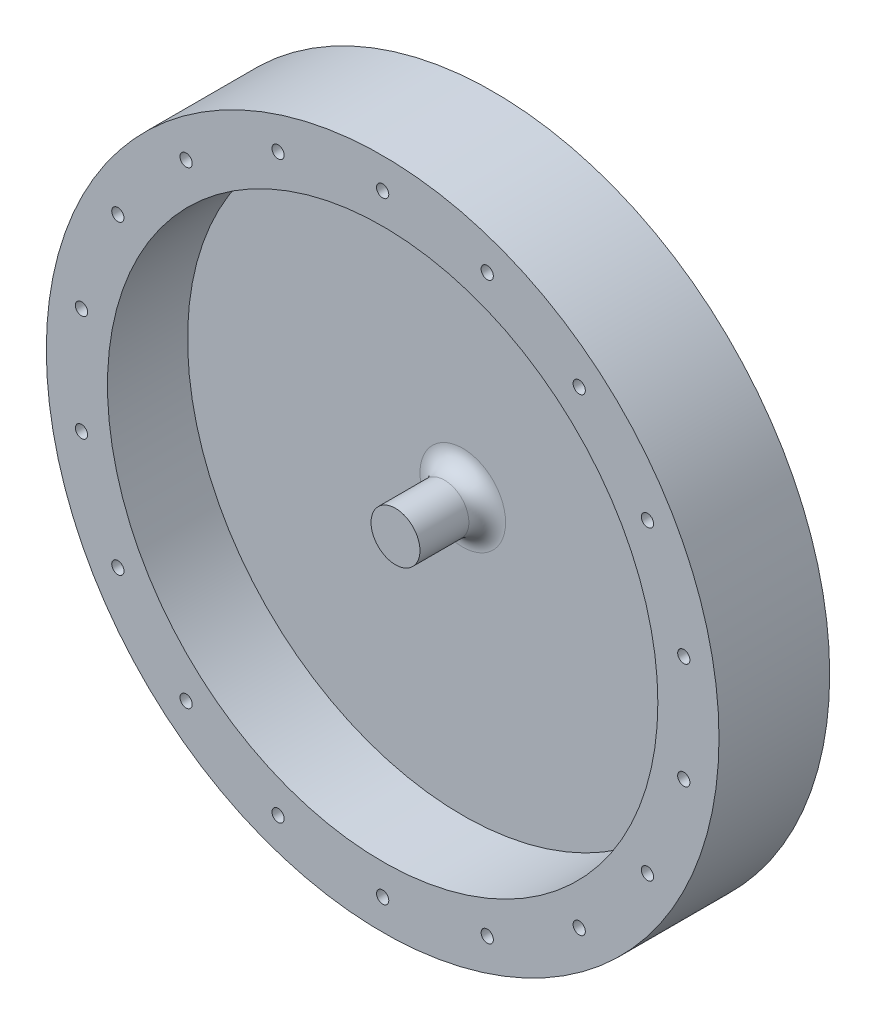
from build123d import *

# Parameters (mm, degrees)
SKETCH1_R                = 4
SKETCH1_R_2              = 2
BOSS_EXTRUDE1_DEPTH      = 8
BOSS_EXTRUDE2_START      = -8
SKETCH2_R                = 45
SKETCH2_R_2              = 4
BOSS_EXTRUDE2_DEPTH      = 5
BOSS_EXTRUDE3_START      = -8
SKETCH3_R                = 55
SKETCH3_R_2              = 45
BOSS_EXTRUDE3_DEPTH      = 18.1
SKETCH4_R                = 2
BOSS_EXTRUDE4_DEPTH      = 2
SKETCH5_R                = 1
CUT_EXTRUDE1_DEPTH       = 5
CIRPATTERN1_COUNT        = 18
MIRROR1_COPY_1_SKETCH_R  = 1
MIRROR1_COPY_1_DEPTH     = 5
MIRROR1_COPY_2_SKETCH_R  = 1
MIRROR1_COPY_2_DEPTH     = 5
MIRROR1_COPY_3_SKETCH_R  = 1
MIRROR1_COPY_3_DEPTH     = 5
MIRROR1_COPY_4_SKETCH_R  = 1
MIRROR1_COPY_4_DEPTH     = 5
MIRROR1_COPY_5_SKETCH_R  = 1
MIRROR1_COPY_5_DEPTH     = 5
MIRROR1_COPY_6_SKETCH_R  = 1
MIRROR1_COPY_6_DEPTH     = 5
MIRROR1_COPY_7_SKETCH_R  = 1
MIRROR1_COPY_7_DEPTH     = 5
MIRROR1_COPY_8_SKETCH_R  = 1
MIRROR1_COPY_8_DEPTH     = 5
MIRROR1_COPY_9_SKETCH_R  = 1
MIRROR1_COPY_9_DEPTH     = 5
MIRROR1_COPY_10_SKETCH_R = 1
MIRROR1_COPY_10_DEPTH    = 5
MIRROR1_COPY_11_SKETCH_R = 1
MIRROR1_COPY_11_DEPTH    = 5
MIRROR1_COPY_12_SKETCH_R = 1
MIRROR1_COPY_12_DEPTH    = 5
MIRROR1_COPY_13_SKETCH_R = 1
MIRROR1_COPY_13_DEPTH    = 5
MIRROR1_COPY_14_SKETCH_R = 1
MIRROR1_COPY_14_DEPTH    = 5
MIRROR1_COPY_15_SKETCH_R = 1
MIRROR1_COPY_15_DEPTH    = 5
MIRROR1_COPY_16_SKETCH_R = 1
MIRROR1_COPY_16_DEPTH    = 5
MIRROR1_COPY_17_SKETCH_R = 1
MIRROR1_COPY_17_DEPTH    = 5
CHAMFER1_SIZE            = 0.5
FILLET1_R                = 3


with BuildPart() as part:
    # Sketch1 → Boss-Extrude1 (new body, symmetric)
    with BuildSketch(Plane.XY):
        Circle(SKETCH1_R)
        Circle(SKETCH1_R_2, mode=Mode.SUBTRACT)
    extrude(amount=BOSS_EXTRUDE1_DEPTH, both=True)

    # Sketch2 → Boss-Extrude2 (add)
    with BuildSketch(Plane.XY.offset(BOSS_EXTRUDE2_START)):
        Circle(SKETCH2_R)
        Circle(SKETCH2_R_2, mode=Mode.SUBTRACT)
    extrude(amount=BOSS_EXTRUDE2_DEPTH)

    # Sketch3 → Boss-Extrude3 (add)
    with BuildSketch(Plane.XY.offset(BOSS_EXTRUDE3_START)):
        Circle(SKETCH3_R)
        Circle(SKETCH3_R_2, mode=Mode.SUBTRACT)
    extrude(amount=BOSS_EXTRUDE3_DEPTH)

    # Sketch4 → Boss-Extrude4 (add)
    with BuildSketch(Plane.XY.offset(8)):
        Circle(SKETCH4_R)
    extrude(amount=-BOSS_EXTRUDE4_DEPTH)

    # Sketch5 → Cut-Extrude1 (cut)
    with BuildSketch(Plane.XY.offset(10.1)):
        with Locations((0, 50)):
            Circle(SKETCH5_R)
    cut_extrude1 = extrude(amount=-CUT_EXTRUDE1_DEPTH, mode=Mode.SUBTRACT)

    # CirPattern1: Cut-Extrude1 ×18 about axis
    cirpattern1_axis = Axis((0, 0, 0), (0, 0, 1))
    for i in range(1, CIRPATTERN1_COUNT):
        add(cut_extrude1.rotate(cirpattern1_axis, i * 360 / CIRPATTERN1_COUNT), mode=Mode.SUBTRACT)

    # Mirror1: Cut-Extrude1 across plane
    add(cut_extrude1.mirror(Plane.XY.offset(1.05)), mode=Mode.SUBTRACT)

    # Mirror1 copy 1 sketch → Mirror1 copy 1 (cut)
    with BuildSketch(Plane(origin=(0, 0, -8), x_dir=(0.939692621, 0.342020143, 0), z_dir=(0, 0, -1))):
        with Locations((0, -50)):
            Circle(MIRROR1_COPY_1_SKETCH_R)
    extrude(amount=-MIRROR1_COPY_1_DEPTH, mode=Mode.SUBTRACT)

    # Mirror1 copy 2 sketch → Mirror1 copy 2 (cut)
    with BuildSketch(Plane(origin=(0, 0, -8), x_dir=(0.766044443, 0.64278761, 0), z_dir=(0, 0, -1))):
        with Locations((0, -50)):
            Circle(MIRROR1_COPY_2_SKETCH_R)
    extrude(amount=-MIRROR1_COPY_2_DEPTH, mode=Mode.SUBTRACT)

    # Mirror1 copy 3 sketch → Mirror1 copy 3 (cut)
    with BuildSketch(Plane(origin=(0, 0, -8), x_dir=(0.5, 0.866025404, 0), z_dir=(0, 0, -1))):
        with Locations((0, -50)):
            Circle(MIRROR1_COPY_3_SKETCH_R)
    extrude(amount=-MIRROR1_COPY_3_DEPTH, mode=Mode.SUBTRACT)

    # Mirror1 copy 4 sketch → Mirror1 copy 4 (cut)
    with BuildSketch(Plane(origin=(0, 0, -8), x_dir=(0.173648178, 0.984807753, 0), z_dir=(0, 0, -1))):
        with Locations((0, -50)):
            Circle(MIRROR1_COPY_4_SKETCH_R)
    extrude(amount=-MIRROR1_COPY_4_DEPTH, mode=Mode.SUBTRACT)

    # Mirror1 copy 5 sketch → Mirror1 copy 5 (cut)
    with BuildSketch(Plane(origin=(0, 0, -8), x_dir=(-0.173648178, 0.984807753, 0), z_dir=(0, 0, -1))):
        with Locations((0, -50)):
            Circle(MIRROR1_COPY_5_SKETCH_R)
    extrude(amount=-MIRROR1_COPY_5_DEPTH, mode=Mode.SUBTRACT)

    # Mirror1 copy 6 sketch → Mirror1 copy 6 (cut)
    with BuildSketch(Plane(origin=(0, 0, -8), x_dir=(-0.5, 0.866025404, 0), z_dir=(0, 0, -1))):
        with Locations((0, -50)):
            Circle(MIRROR1_COPY_6_SKETCH_R)
    extrude(amount=-MIRROR1_COPY_6_DEPTH, mode=Mode.SUBTRACT)

    # Mirror1 copy 7 sketch → Mirror1 copy 7 (cut)
    with BuildSketch(Plane(origin=(0, 0, -8), x_dir=(-0.766044443, 0.64278761, 0), z_dir=(0, 0, -1))):
        with Locations((0, -50)):
            Circle(MIRROR1_COPY_7_SKETCH_R)
    extrude(amount=-MIRROR1_COPY_7_DEPTH, mode=Mode.SUBTRACT)

    # Mirror1 copy 8 sketch → Mirror1 copy 8 (cut)
    with BuildSketch(Plane(origin=(0, 0, -8), x_dir=(-0.939692621, 0.342020143, 0), z_dir=(0, 0, -1))):
        with Locations((0, -50)):
            Circle(MIRROR1_COPY_8_SKETCH_R)
    extrude(amount=-MIRROR1_COPY_8_DEPTH, mode=Mode.SUBTRACT)

    # Mirror1 copy 9 sketch → Mirror1 copy 9 (cut)
    with BuildSketch(Plane(origin=(0, 0, -8), x_dir=(-1, 0, 0), z_dir=(0, 0, -1))):
        with Locations((0, -50)):
            Circle(MIRROR1_COPY_9_SKETCH_R)
    extrude(amount=-MIRROR1_COPY_9_DEPTH, mode=Mode.SUBTRACT)

    # Mirror1 copy 10 sketch → Mirror1 copy 10 (cut)
    with BuildSketch(Plane(origin=(0, 0, -8), x_dir=(-0.939692621, -0.342020143, 0), z_dir=(0, 0, -1))):
        with Locations((0, -50)):
            Circle(MIRROR1_COPY_10_SKETCH_R)
    extrude(amount=-MIRROR1_COPY_10_DEPTH, mode=Mode.SUBTRACT)

    # Mirror1 copy 11 sketch → Mirror1 copy 11 (cut)
    with BuildSketch(Plane(origin=(0, 0, -8), x_dir=(-0.766044443, -0.64278761, 0), z_dir=(0, 0, -1))):
        with Locations((0, -50)):
            Circle(MIRROR1_COPY_11_SKETCH_R)
    extrude(amount=-MIRROR1_COPY_11_DEPTH, mode=Mode.SUBTRACT)

    # Mirror1 copy 12 sketch → Mirror1 copy 12 (cut)
    with BuildSketch(Plane(origin=(0, 0, -8), x_dir=(-0.5, -0.866025404, 0), z_dir=(0, 0, -1))):
        with Locations((0, -50)):
            Circle(MIRROR1_COPY_12_SKETCH_R)
    extrude(amount=-MIRROR1_COPY_12_DEPTH, mode=Mode.SUBTRACT)

    # Mirror1 copy 13 sketch → Mirror1 copy 13 (cut)
    with BuildSketch(Plane(origin=(0, 0, -8), x_dir=(-0.173648178, -0.984807753, 0), z_dir=(0, 0, -1))):
        with Locations((0, -50)):
            Circle(MIRROR1_COPY_13_SKETCH_R)
    extrude(amount=-MIRROR1_COPY_13_DEPTH, mode=Mode.SUBTRACT)

    # Mirror1 copy 14 sketch → Mirror1 copy 14 (cut)
    with BuildSketch(Plane(origin=(0, 0, -8), x_dir=(0.173648178, -0.984807753, 0), z_dir=(0, 0, -1))):
        with Locations((0, -50)):
            Circle(MIRROR1_COPY_14_SKETCH_R)
    extrude(amount=-MIRROR1_COPY_14_DEPTH, mode=Mode.SUBTRACT)

    # Mirror1 copy 15 sketch → Mirror1 copy 15 (cut)
    with BuildSketch(Plane(origin=(0, 0, -8), x_dir=(0.5, -0.866025404, 0), z_dir=(0, 0, -1))):
        with Locations((0, -50)):
            Circle(MIRROR1_COPY_15_SKETCH_R)
    extrude(amount=-MIRROR1_COPY_15_DEPTH, mode=Mode.SUBTRACT)

    # Mirror1 copy 16 sketch → Mirror1 copy 16 (cut)
    with BuildSketch(Plane(origin=(0, 0, -8), x_dir=(0.766044443, -0.64278761, 0), z_dir=(0, 0, -1))):
        with Locations((0, -50)):
            Circle(MIRROR1_COPY_16_SKETCH_R)
    extrude(amount=-MIRROR1_COPY_16_DEPTH, mode=Mode.SUBTRACT)

    # Mirror1 copy 17 sketch → Mirror1 copy 17 (cut)
    with BuildSketch(Plane(origin=(0, 0, -8), x_dir=(0.939692621, -0.342020143, 0), z_dir=(0, 0, -1))):
        with Locations((0, -50)):
            Circle(MIRROR1_COPY_17_SKETCH_R)
    extrude(amount=-MIRROR1_COPY_17_DEPTH, mode=Mode.SUBTRACT)

    # Chamfer1
    chamfer1_edges = [part.edges().sort_by_distance(p)[0] for p in [
        (-2, 0, -8),
    ]]
    chamfer(chamfer1_edges, length=CHAMFER1_SIZE)

    # Fillet1
    fillet1_edges = [part.edges().sort_by_distance(p)[0] for p in [
        (-4, 0, -3),
    ]]
    fillet(fillet1_edges, radius=FILLET1_R)


solid = part.part
